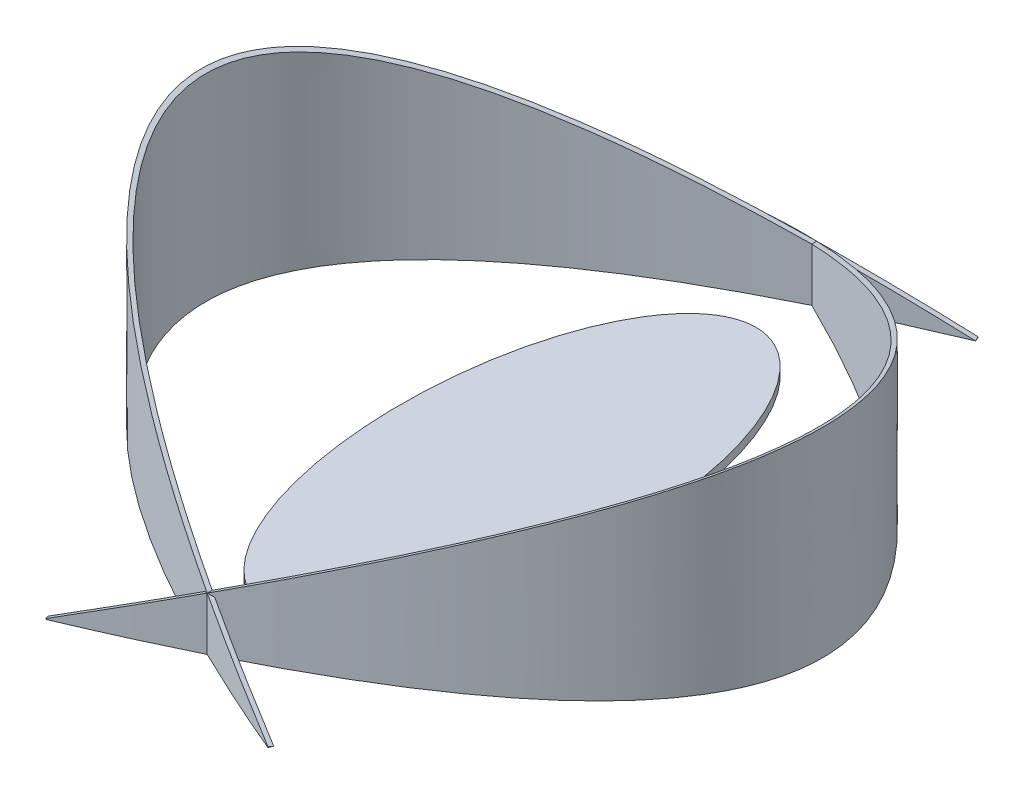
from build123d import *

# Parameters (mm, degrees)
SKETCH1_RX         = 55
SKETCH1_RY         = 25
EXTRUDE1_DEPTH     = 2
EXTRUDE2_DEPTH     = 45
CUT_EXTRUDE1_DEPTH = 82.5


with BuildPart() as part:
    # Sketch1 → Extrude1 (new body)
    with BuildSketch(Plane(origin=(0, 0, 0), x_dir=(1, 0, 0), z_dir=(0, 1, 0))):
        with Locations(Location((0, 0), (0, 0, 90))):
            Ellipse(SKETCH1_RX, SKETCH1_RY)
    extrude(amount=EXTRUDE1_DEPTH)


with BuildPart() as body_2:
    # Sketch2 → Extrude2 (new body)
    with BuildSketch(Plane(origin=(0, 0, 0), x_dir=(1, 0, 0), z_dir=(0, 1, 0))):
        with BuildLine():
            Line((-25.388057017, 79.078364585), (-25, 80))
            add(Edge.make_bspline(
                [(-25, 80), (165, 0), (-25, -80)],
                knots=[0, 0, 0, 1, 1, 1], degree=2))
            Line((-25, -80), (-25.388057017, -79.078364585))
            add(Edge.make_bspline(
                [(-25.388057017, 79.078364585), (-24.406776541, 78.665193858), (-22.43698278, 77.829307882), (-18.583242297, 76.167689289), (-13.874190796, 74.08746301), (-8.412941586, 71.59308891), (-1.378255597, 68.26737178), (6.949204529, 64.111712915), (16.197223053, 59.127464661), (24.699694592, 54.1465255), (35.041816476, 47.510851938), (46.103709226, 39.22938896), (56.390910528, 29.325832239), (63.695807241, 19.476755348), (68.041731822, 9.703913712), (69.479134024, 0), (68.041731822, -9.703913712), (63.695807241, -19.476755348), (56.390910528, -29.325832239), (46.103709226, -39.22938896), (35.041816476, -47.510851938), (24.699694592, -54.1465255), (16.197223052, -59.127464662), (6.949204529, -64.111712915), (-1.378255597, -68.26737178), (-8.412941586, -71.59308891), (-13.874190796, -74.08746301), (-18.583242297, -76.167689289), (-22.43698278, -77.829307882), (-24.406776542, -78.665193859), (-25.388057017, -79.078364585)],
                knots=[0.489102753, 0.489102753, 0.489102753, 0.489102753, 0.489273022, 0.489443292, 0.489783831, 0.49012437, 0.490464909, 0.491145987, 0.491827064, 0.492508142, 0.49318922, 0.494551376, 0.495913532, 0.497275688, 0.498637844, 0.5, 0.501362156, 0.502724312, 0.504086468, 0.505448624, 0.50681078, 0.507491858, 0.508172936, 0.508854013, 0.509535091, 0.50987563, 0.510216169, 0.510556708, 0.510726978, 0.510897247, 0.510897247, 0.510897247, 0.510897247], degree=3))
        make_face()
    extrude(amount=EXTRUDE2_DEPTH)

    # Sketch3 → Cut-Extrude1 (cut, symmetric)
    with BuildSketch(Plane.XY):
        Polygon((70, 45), (-25.388057017, 45), (-25.388057017, -5e-09), align=None)
    extrude(amount=CUT_EXTRUDE1_DEPTH, both=True, mode=Mode.SUBTRACT)

    # Mirror1: body 2 across plane


with BuildPart() as body_2_1:
    add(body_2.part)
    add(body_2.part.mirror(Plane(origin=(0, 0, 0), x_dir=(0, 0, 1), z_dir=(1, 0, 0))))


solid = Compound([part.part, body_2_1.part])
